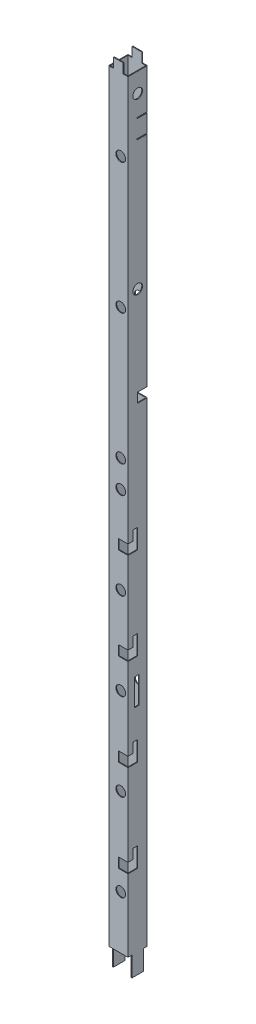
from build123d import *

# Parameters (mm, degrees)
SKETCH1_W           = 37
SKETCH1_H           = 37
BOSS_EXTRUDE1_DEPTH = 1637.5
SKETCH2_W           = 10
SKETCH2_H           = 20
CUT_EXTRUDE1_DEPTH  = 40
SKETCH3_W           = 21
SKETCH3_H           = 2
CUT_EXTRUDE2_DEPTH  = 20
SKETCH4_W           = 8.1
SKETCH4_H           = 41
CUT_EXTRUDE3_DEPTH  = 1639.476807892
CUT_EXTRUDE4_DEPTH  = 20
SKETCH6_W           = 20
SKETCH6_H           = 20
CUT_EXTRUDE5_DEPTH  = 20
SKETCH7_R           = 10
CUT_EXTRUDE6_DEPTH  = 1639.476807892
SKETCH8_R           = 10
CUT_EXTRUDE7_DEPTH  = 1639.476807892
SKETCH9_W           = 10
SKETCH9_H           = 55
CUT_EXTRUDE8_DEPTH  = 10


with BuildPart() as part:
    # Sketch1 → Boss-Extrude1 (new body)
    with BuildSketch(Plane(origin=(0, 0, 0), x_dir=(1, 0, 0), z_dir=(0, 1, 0))):
        with BuildLine():
            Line((0.5, 0), (39.5, 0))
            ThreePointArc((39.5, 0), (39.853553391, 0.146446609), (40, 0.5))
            Line((40, 0.5), (40, 39.5))
            ThreePointArc((40, 39.5), (39.853553391, 39.853553391), (39.5, 40))
            Line((39.5, 40), (0.5, 40))
            ThreePointArc((0.5, 40), (0.146446609, 39.853553391), (0, 39.5))
            Line((0, 39.5), (0, 0.5))
            ThreePointArc((0, 0.5), (0.146446609, 0.146446609), (0.5, 0))
        make_face()
        with Locations((20, 20)):
            Rectangle(SKETCH1_W, SKETCH1_H, mode=Mode.SUBTRACT)
    extrude(amount=BOSS_EXTRUDE1_DEPTH)

    # Sketch2 → Cut-Extrude1 (cut)
    with BuildSketch(Plane.XY.offset(-40)):
        with Locations((35, 1627.5)):
            Rectangle(SKETCH2_W, SKETCH2_H)
        with Locations((5, 1627.5)):
            Rectangle(SKETCH2_W, SKETCH2_H)
    extrude(amount=CUT_EXTRUDE1_DEPTH, mode=Mode.SUBTRACT)

    # Sketch3 → Cut-Extrude2 (cut)
    with BuildSketch(Plane(origin=(40, 0, 0), x_dir=(0, 0, -1), z_dir=(1, 0, 0))):
        with Locations((29.5, 1534)):
            Rectangle(SKETCH3_W, SKETCH3_H)
        with Locations((29.5, 1496)):
            Rectangle(SKETCH3_W, SKETCH3_H)
    extrude(amount=-CUT_EXTRUDE2_DEPTH, mode=Mode.SUBTRACT)

    # Sketch4 → Cut-Extrude3 (cut, through all)
    with BuildSketch(Plane.ZY):
        with Locations((-4.05, 20.5)):
            Rectangle(SKETCH4_W, SKETCH4_H)
        with Locations((-35.95, 20.5)):
            Rectangle(SKETCH4_W, SKETCH4_H)
    extrude(amount=-CUT_EXTRUDE3_DEPTH, mode=Mode.SUBTRACT)

    # Sketch5 → Cut-Extrude4 (cut)
    with BuildSketch(Plane(origin=(40, 0, -40), x_dir=(0, 0, 1), z_dir=(-1, 0, 0))):
        Polygon((40, 190.5), (20, 190.5), (20, 231), (30, 231), (30, 211), (40, 211), align=None)
        Polygon((40, 380.5), (20, 380.5), (20, 421), (30, 421), (30, 401), (40, 401), align=None)
        Polygon((40, 570.5), (20, 570.5), (20, 611), (30, 611), (30, 591), (40, 591), align=None)
        Polygon((40, 760.5), (20, 760.5), (20, 801), (30, 801), (30, 781), (40, 781), align=None)
    extrude(amount=CUT_EXTRUDE4_DEPTH, mode=Mode.SUBTRACT)

    # Sketch6 → Cut-Extrude5 (cut)
    with BuildSketch(Plane(origin=(0, 0, -40), x_dir=(-1, 0, 0), z_dir=(0, 0, -1))):
        with Locations((-30, 1033)):
            Rectangle(SKETCH6_W, SKETCH6_H)
    extrude(amount=-CUT_EXTRUDE5_DEPTH, mode=Mode.SUBTRACT)

    # Sketch7 → Cut-Extrude6 (cut, through all)
    with BuildSketch(Plane(origin=(40, 0, 0), x_dir=(0, 0, -1), z_dir=(1, 0, 0))):
        with Locations((20, 1577.5)):
            Circle(SKETCH7_R)
        with Locations((20, 1227.5)):
            Circle(SKETCH7_R)
    extrude(amount=-CUT_EXTRUDE6_DEPTH, mode=Mode.SUBTRACT)

    # Sketch8 → Cut-Extrude7 (cut, through all)
    with BuildSketch(Plane.XY):
        with Locations((25, 1467.5)):
            Circle(SKETCH8_R)
        with Locations((25, 1197.5)):
            Circle(SKETCH8_R)
        with Locations((25, 927.5)):
            Circle(SKETCH8_R)
        with Locations((25, 151)):
            Circle(SKETCH8_R)
        with Locations((25, 331)):
            Circle(SKETCH8_R)
        with Locations((25, 511)):
            Circle(SKETCH8_R)
        with Locations((25, 691)):
            Circle(SKETCH8_R)
        with Locations((25, 871)):
            Circle(SKETCH8_R)
    extrude(amount=-CUT_EXTRUDE7_DEPTH, mode=Mode.SUBTRACT)

    # Sketch9 → Cut-Extrude8 (cut)
    with BuildSketch(Plane(origin=(40, 0, 0), x_dir=(0, 0, -1), z_dir=(1, 0, 0))):
        with Locations((18, 508.5)):
            Rectangle(SKETCH9_W, SKETCH9_H)
    extrude(amount=-CUT_EXTRUDE8_DEPTH, mode=Mode.SUBTRACT)


solid = part.part
